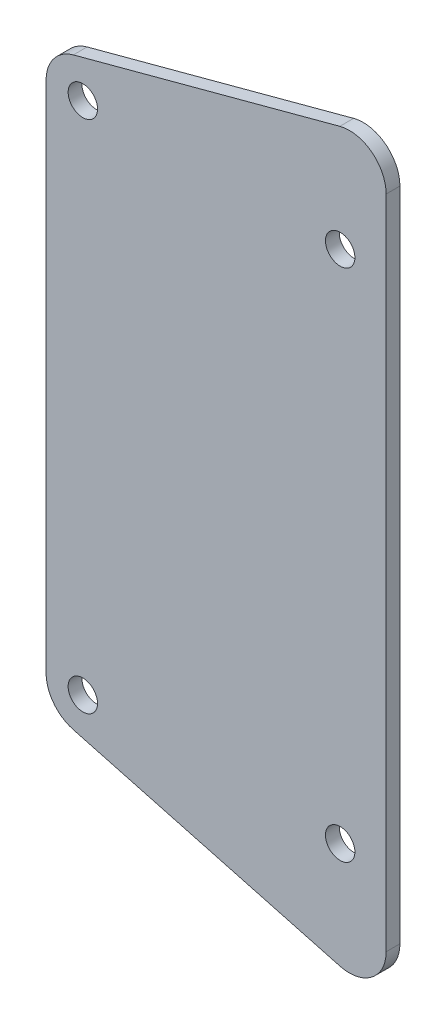
from build123d import *

# Parameters (mm, degrees)
SKETCH1_R           = 1.6
BOSS_EXTRUDE1_DEPTH = 1.5
CUT_EXTRUDE1_DEPTH  = 1.5
BOSS_EXTRUDE2_DEPTH = 1.5
FILLET1_R           = 4


with BuildPart() as part:
    # Sketch1 → Boss-Extrude1 (new body)
    with BuildSketch(Plane.XY):
        Polygon((5, 59), (-32, 72.466898668), (-32, 56), (-32, 0), (-32, -16.466898668), (5, -3), align=None)
        Circle(SKETCH1_R, mode=Mode.SUBTRACT)
        with Locations((-28, 0)):
            Circle(SKETCH1_R, mode=Mode.SUBTRACT)
        with Locations((0, 56)):
            Circle(SKETCH1_R, mode=Mode.SUBTRACT)
        with Locations((-28, 56)):
            Circle(SKETCH1_R, mode=Mode.SUBTRACT)
    extrude(amount=BOSS_EXTRUDE1_DEPTH)

    # Sketch2 → Cut-Extrude1 (cut)
    with BuildSketch(Plane.XY.offset(1.5)):
        Polygon((5, 59), (-43.875673323, 59), (-43.875673323, 79.145449881), (45.915909875, 71.47170947), align=None)
        Polygon((5, -3), (-36.907564214, -3), (-45.551547665, -23.435700668), (23.159300381, -21.407010674), align=None)
    extrude(amount=-CUT_EXTRUDE1_DEPTH, mode=Mode.SUBTRACT)

    # Sketch3 → Boss-Extrude2 (add)
    with BuildSketch(Plane.XY.offset(1.5)):
        Polygon((-32, 59), (5, 68.91412012), (5, 59), align=None)
        Polygon((5, -3), (5, -12.91412012), (-32, -3), align=None)
    extrude(amount=-BOSS_EXTRUDE2_DEPTH)

    # Fillet1
    fillet1_edges = [part.edges().sort_by_distance(p)[0] for p in [
        (-32, 59, 0.75),
        (-32, -3, 0.75),
        (5, 68.91412012, 0.75),
        (5, -12.91412012, 0.75),
    ]]
    fillet(fillet1_edges, radius=FILLET1_R)


solid = part.part
